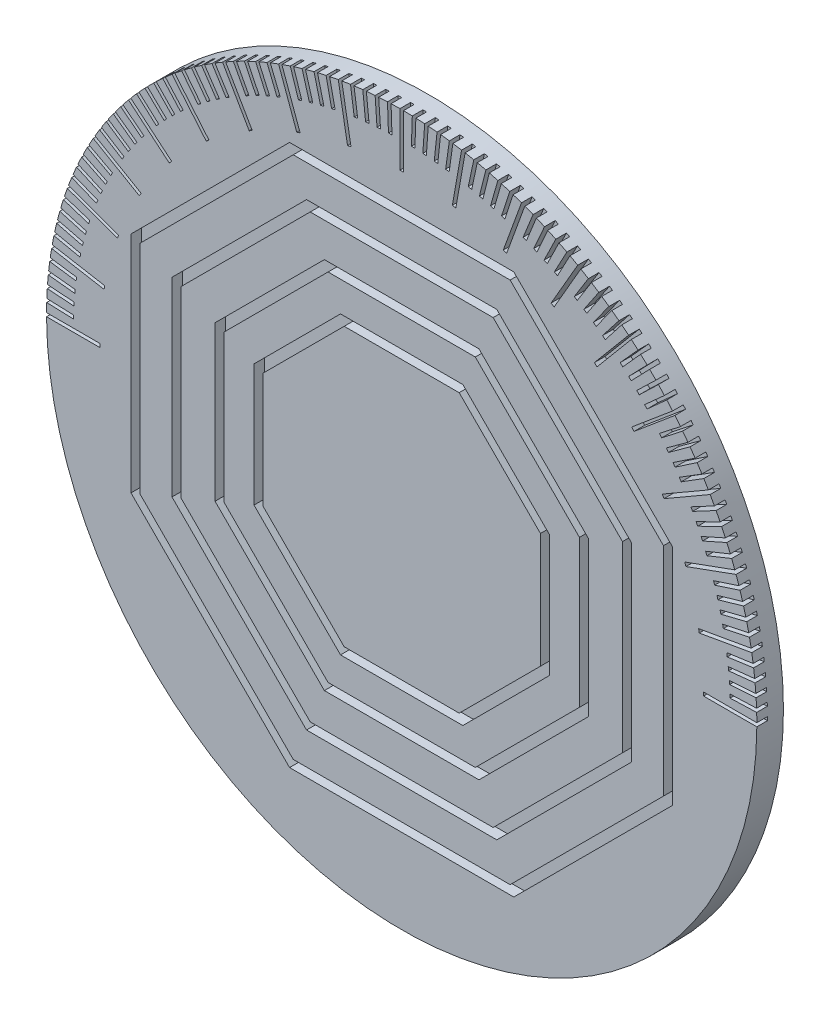
from build123d import *

# Parameters (mm, degrees)
SKETCH_1_R          = 40
EXTRUDE_1_DEPTH     = 3
CUT_EXTRUDE_2_DEPTH = 1.2
SKETCH_6_W          = 3
SKETCH_6_H          = 0.4
SKETCH_6_W_2        = 0.4
SKETCH_6_H_2        = 3
CUT_EXTRUDE_5_DEPTH = 1.2
SKETCH_4_W          = 6
SKETCH_4_H          = 0.4
SKETCH_4_W_2        = 0.4
SKETCH_4_H_2        = 6
CUT_EXTRUDE_7_DEPTH = 1.2


with BuildPart() as part:
    # 스케치1 → 보스-돌출1 (new body)
    with BuildSketch(Plane.XY):
        Circle(SKETCH_1_R)
    extrude(amount=EXTRUDE_1_DEPTH)

    # 스케치3 → 컷-돌출2 (cut)
    # profile 1 of 4: a face of its own
    with BuildSketch(Plane.XY.offset(3)):
        Polygon((-12.628553268, -30.488024573), (12.628553268, -30.488024573), (30.488024573, -12.628553268), (30.488024573, 12.628553268), (12.628553268, 30.488024573), (-12.628553268, 30.488024573), (-30.488024573, 12.628553268), (-30.488024573, -12.628553268), align=None)
        Polygon((29.488024573, -12.214339706), (12.214339706, -29.488024573), (-12.214339706, -29.488024573), (-29.488024573, -12.214339706), (-29.488024573, 12.214339706), (-12.214339706, 29.488024573), (12.214339706, 29.488024573), (29.488024573, 12.214339706), align=None, mode=Mode.SUBTRACT)
    # profile 2 of 4: a face of its own
    with BuildSketch(Plane.XY.offset(3)):
        Polygon((10.715136106, 25.86862691), (-10.715136106, 25.86862691), (-25.86862691, 10.715136106), (-25.86862691, -10.715136106), (-10.715136106, -25.86862691), (10.715136106, -25.86862691), (25.86862691, -10.715136106), (25.86862691, 10.715136106), align=None)
        Polygon((-24.86862691, 10.300922544), (-10.300922544, 24.86862691), (10.300922544, 24.86862691), (24.86862691, 10.300922544), (24.86862691, -10.300922544), (10.300922544, -24.86862691), (-10.300922544, -24.86862691), (-24.86862691, -10.300922544), align=None, mode=Mode.SUBTRACT)
    # profile 3 of 4: a face of its own
    with BuildSketch(Plane.XY.offset(3)):
        Polygon((8.706048086, 21.018259365), (-8.706048086, 21.018259365), (-21.018259365, 8.706048086), (-21.018259365, -8.706048086), (-8.706048086, -21.018259365), (8.706048086, -21.018259365), (21.018259365, -8.706048086), (21.018259365, 8.706048086), align=None)
        Polygon((-20.018259365, 8.291834524), (-8.291834524, 20.018259365), (8.291834524, 20.018259365), (20.018259365, 8.291834524), (20.018259365, -8.291834524), (8.291834524, -20.018259365), (-8.291834524, -20.018259365), (-20.018259365, -8.291834524), align=None, mode=Mode.SUBTRACT)
    # profile 4 of 4: a face of its own
    with BuildSketch(Plane.XY.offset(3)):
        Polygon((-6.888301783, -16.629831585), (6.888301783, -16.629831585), (16.629831585, -6.888301783), (16.629831585, 6.888301783), (6.888301783, 16.629831585), (-6.888301783, 16.629831585), (-16.629831585, 6.888301783), (-16.629831585, -6.888301783), align=None)
        Polygon((15.629831585, -6.47408822), (6.47408822, -15.629831585), (-6.47408822, -15.629831585), (-15.629831585, -6.47408822), (-15.629831585, 6.47408822), (-6.47408822, 15.629831585), (6.47408822, 15.629831585), (15.629831585, 6.47408822), align=None, mode=Mode.SUBTRACT)
    extrude(amount=-CUT_EXTRUDE_2_DEPTH, mode=Mode.SUBTRACT)

    # 스케치6 → 컷-돌출5 (cut)
    with BuildSketch(Plane.XY.offset(3)):
        with Locations((-38.5, 0)):
            Rectangle(SKETCH_6_W, SKETCH_6_H)
        Polygon((-39.968653181, 1.595858034), (-39.98261298, 1.196101703), (-36.984440499, 1.091403213), (-36.9704807, 1.491159543), align=None)
        Polygon((-39.888610716, 2.98977176), (-39.916513305, 2.59074614), (-36.923821154, 2.381476718), (-36.895918565, 2.780502339), align=None)
        Polygon((-39.759970122, 4.38004291), (-39.801781507, 3.982234152), (-36.818215821, 3.668648762), (-36.776404436, 4.06645752), align=None)
        Polygon((-39.582888129, 5.764977652), (-39.63855737, 5.368870425), (-36.667753164, 4.951351122), (-36.612083923, 5.347458349), align=None)
        Polygon((-39.357580485, 7.142888657), (-39.427039756, 6.748965556), (-36.472616497, 6.228021023), (-36.403157226, 6.621944124), align=None)
        Polygon((-39.084321691, 8.512097153), (-39.167486368, 8.120838113), (-36.233043565, 7.49710304), (-36.149878889, 7.88836208), align=None)
        Polygon((-38.763444672, 9.870934969), (-38.86021343, 9.482816679), (-35.949326251, 8.757050992), (-35.852557493, 9.145169282), align=None)
        Polygon((-38.395340366, 11.217746572), (-38.505595309, 10.833241893), (-35.621810221, 10.006329826), (-35.511555279, 10.390834504), align=None)
        Polygon((-37.980457253, 12.550891078), (-38.104064051, 12.170468472), (-35.250894502, 11.243417489), (-35.127287704, 11.623840095), align=None)
        Polygon((-37.519300803, 13.868744257), (-37.65610886, 13.492867209), (-34.837030998, 12.466806779), (-34.70022294, 12.842683827), align=None)
        Polygon((-37.012432864, 15.169700508), (-37.162275501, 14.798826966), (-34.380723938, 13.675007185), (-34.2308813, 14.045880727), align=None)
        Polygon((-36.460470977, 16.452174815), (-36.623165634, 16.086756632), (-33.882529261, 14.866546702), (-33.719834604, 15.231964885), align=None)
        Polygon((-35.864087623, 17.714604681), (-36.039436081, 17.355087062), (-33.343053942, 16.039973622), (-33.167705484, 16.39949124), align=None)
        Polygon((-35.224009402, 18.95545203), (-35.411798027, 18.602272993), (-32.762955248, 17.193858305), (-32.575166623, 17.547037342), align=None)
        Polygon((-34.541016151, 20.173205081), (-34.741016151, 19.826794919), (-32.14293994, 18.326794919), (-31.94293994, 18.673205081), align=None)
        Polygon((-33.815939993, 21.366380189), (-34.027907699, 21.02716095), (-31.483763411, 19.437403157), (-31.271795705, 19.776622396), align=None)
        Polygon((-33.049664322, 22.533523653), (-33.273341483, 22.201908624), (-30.786228765, 20.524329914), (-30.562551604, 20.855944943), align=None)
        Polygon((-32.243122725, 23.673213491), (-32.478236825, 23.349606693), (-30.051185842, 21.586250936), (-29.816071741, 21.909857734), align=None)
        Polygon((-31.397297849, 24.784061164), (-31.643562439, 24.468856862), (-29.279530179, 22.621872436), (-29.033265588, 22.937076738), align=None)
        Polygon((-30.513220203, 25.864713276), (-30.770335247, 25.558295499), (-28.472201917, 23.62993267), (-28.215086873, 23.936350447), align=None)
        Polygon((-29.591966898, 26.913853219), (-29.85961914, 26.616595289), (-27.630184664, 24.60920347), (-27.362532421, 24.9064614), align=None)
        Polygon((-28.634660339, 27.930202778), (-28.912523688, 27.642466858), (-26.754504287, 25.558491747), (-26.476640938, 25.846227667), align=None)
        Polygon((-27.642466858, 28.912523688), (-27.930202778, 28.634660339), (-25.846227667, 26.476640938), (-25.558491747, 26.754504287), align=None)
        Polygon((-26.616595289, 29.85961914), (-26.913853219, 29.591966898), (-24.9064614, 27.362532421), (-24.60920347, 27.630184664), align=None)
        Polygon((-25.558295499, 30.770335247), (-25.864713276, 30.513220203), (-23.936350447, 28.215086873), (-23.62993267, 28.472201917), align=None)
        Polygon((-24.468856862, 31.643562439), (-24.784061164, 31.397297849), (-22.937076738, 29.033265588), (-22.621872436, 29.279530179), align=None)
        Polygon((-23.349606693, 32.478236825), (-23.673213491, 32.243122725), (-21.909857734, 29.816071741), (-21.586250936, 30.051185842), align=None)
        Polygon((-22.201908624, 33.273341483), (-22.533523653, 33.049664322), (-20.855944943, 30.562551604), (-20.524329914, 30.786228765), align=None)
        Polygon((-21.02716095, 34.027907699), (-21.366380189, 33.815939993), (-19.776622396, 31.271795705), (-19.437403157, 31.483763411), align=None)
        Polygon((-19.826794919, 34.741016151), (-20.173205081, 34.541016151), (-18.673205081, 31.94293994), (-18.326794919, 32.14293994), align=None)
        Polygon((-18.602272993, 35.411798027), (-18.95545203, 35.224009402), (-17.547037342, 32.575166623), (-17.193858305, 32.762955248), align=None)
        Polygon((-17.355087062, 36.039436081), (-17.714604681, 35.864087623), (-16.39949124, 33.167705484), (-16.039973622, 33.343053942), align=None)
        Polygon((-16.086756632, 36.623165634), (-16.452174815, 36.460470977), (-15.231964885, 33.719834604), (-14.866546702, 33.882529261), align=None)
        Polygon((-14.798826966, 37.162275501), (-15.169700508, 37.012432864), (-14.045880727, 34.2308813), (-13.675007185, 34.380723938), align=None)
        Polygon((-13.492867209, 37.65610886), (-13.868744257, 37.519300803), (-12.842683827, 34.70022294), (-12.466806779, 34.837030998), align=None)
        Polygon((-12.170468472, 38.104064051), (-12.550891078, 37.980457253), (-11.623840095, 35.127287704), (-11.243417489, 35.250894502), align=None)
        Polygon((-10.833241893, 38.505595309), (-11.217746572, 38.395340366), (-10.390834504, 35.511555279), (-10.006329826, 35.621810221), align=None)
        Polygon((-9.482816679, 38.86021343), (-9.870934969, 38.763444672), (-9.145169282, 35.852557493), (-8.757050992, 35.949326251), align=None)
        Polygon((-8.120838113, 39.167486368), (-8.512097153, 39.084321691), (-7.88836208, 36.149878889), (-7.49710304, 36.233043565), align=None)
        Polygon((-6.748965556, 39.427039756), (-7.142888657, 39.357580485), (-6.621944124, 36.403157226), (-6.228021023, 36.472616497), align=None)
        Polygon((-5.368870425, 39.63855737), (-5.764977652, 39.582888129), (-5.347458349, 36.612083923), (-4.951351122, 36.667753164), align=None)
        Polygon((-3.982234152, 39.801781507), (-4.38004291, 39.759970122), (-4.06645752, 36.776404436), (-3.668648762, 36.818215821), align=None)
        Polygon((-2.59074614, 39.916513305), (-2.98977176, 39.888610716), (-2.780502339, 36.895918565), (-2.381476718, 36.923821154), align=None)
        Polygon((-1.196101703, 39.98261298), (-1.595858034, 39.968653181), (-1.491159543, 36.9704807), (-1.091403213, 36.984440499), align=None)
        with Locations((0, 38.5)):
            Rectangle(SKETCH_6_W_2, SKETCH_6_H_2)
        Polygon((1.595858033, 39.968653181), (1.196101703, 39.98261298), (1.091403213, 36.984440499), (1.491159543, 36.9704807), align=None)
        Polygon((2.98977176, 39.888610716), (2.59074614, 39.916513305), (2.381476718, 36.923821154), (2.780502339, 36.895918565), align=None)
        Polygon((4.38004291, 39.759970122), (3.982234152, 39.801781507), (3.668648762, 36.818215821), (4.06645752, 36.776404436), align=None)
        Polygon((5.764977652, 39.582888129), (5.368870425, 39.63855737), (4.951351122, 36.667753164), (5.347458349, 36.612083923), align=None)
        Polygon((7.142888657, 39.357580485), (6.748965556, 39.427039756), (6.228021023, 36.472616497), (6.621944124, 36.403157226), align=None)
        Polygon((8.512097153, 39.084321691), (8.120838113, 39.167486368), (7.49710304, 36.233043565), (7.88836208, 36.149878889), align=None)
        Polygon((9.870934969, 38.763444672), (9.482816679, 38.86021343), (8.757050992, 35.949326251), (9.145169282, 35.852557493), align=None)
        Polygon((11.217746572, 38.395340366), (10.833241893, 38.505595309), (10.006329826, 35.621810221), (10.390834504, 35.511555279), align=None)
        Polygon((12.550891078, 37.980457253), (12.170468472, 38.104064051), (11.243417489, 35.250894502), (11.623840095, 35.127287704), align=None)
        Polygon((13.868744257, 37.519300803), (13.492867209, 37.65610886), (12.466806779, 34.837030998), (12.842683827, 34.70022294), align=None)
        Polygon((15.169700508, 37.012432864), (14.798826966, 37.162275501), (13.675007185, 34.380723938), (14.045880727, 34.2308813), align=None)
        Polygon((16.452174815, 36.460470977), (16.086756631, 36.623165634), (14.866546702, 33.882529261), (15.231964885, 33.719834604), align=None)
        Polygon((17.714604681, 35.864087623), (17.355087062, 36.039436081), (16.039973622, 33.343053942), (16.39949124, 33.167705484), align=None)
        Polygon((18.95545203, 35.224009402), (18.602272993, 35.411798027), (17.193858304, 32.762955248), (17.547037342, 32.575166623), align=None)
        Polygon((20.173205081, 34.541016151), (19.826794919, 34.741016151), (18.326794919, 32.14293994), (18.673205081, 31.94293994), align=None)
        Polygon((21.366380189, 33.815939993), (21.02716095, 34.027907699), (19.437403157, 31.483763411), (19.776622396, 31.271795705), align=None)
        Polygon((22.533523653, 33.049664322), (22.201908624, 33.273341483), (20.524329914, 30.786228765), (20.855944943, 30.562551604), align=None)
        Polygon((23.673213491, 32.243122725), (23.349606693, 32.478236825), (21.586250936, 30.051185842), (21.909857734, 29.816071741), align=None)
        Polygon((24.784061164, 31.397297849), (24.468856862, 31.643562439), (22.621872436, 29.279530179), (22.937076738, 29.033265588), align=None)
        Polygon((25.864713276, 30.513220203), (25.558295499, 30.770335247), (23.62993267, 28.472201917), (23.936350447, 28.215086873), align=None)
        Polygon((26.913853219, 29.591966898), (26.616595289, 29.85961914), (24.60920347, 27.630184664), (24.9064614, 27.362532421), align=None)
        Polygon((27.930202778, 28.634660339), (27.642466858, 28.912523688), (25.558491747, 26.754504287), (25.846227667, 26.476640938), align=None)
        Polygon((28.912523688, 27.642466858), (28.634660339, 27.930202778), (26.476640938, 25.846227667), (26.754504287, 25.558491747), align=None)
        Polygon((29.85961914, 26.616595289), (29.591966898, 26.913853219), (27.362532421, 24.9064614), (27.630184664, 24.60920347), align=None)
        Polygon((30.770335247, 25.558295499), (30.513220203, 25.864713276), (28.215086873, 23.936350447), (28.472201917, 23.62993267), align=None)
        Polygon((31.643562439, 24.468856862), (31.397297849, 24.784061164), (29.033265588, 22.937076738), (29.279530179, 22.621872436), align=None)
        Polygon((32.478236825, 23.349606693), (32.243122725, 23.673213491), (29.816071741, 21.909857734), (30.051185842, 21.586250936), align=None)
        Polygon((33.273341483, 22.201908624), (33.049664322, 22.533523653), (30.562551604, 20.855944943), (30.786228765, 20.524329914), align=None)
        Polygon((34.027907699, 21.02716095), (33.815939993, 21.366380189), (31.271795705, 19.776622396), (31.483763411, 19.437403157), align=None)
        Polygon((34.741016151, 19.826794919), (34.541016151, 20.173205081), (31.94293994, 18.673205081), (32.14293994, 18.326794919), align=None)
        Polygon((35.411798027, 18.602272993), (35.224009402, 18.95545203), (32.575166623, 17.547037342), (32.762955248, 17.193858305), align=None)
        Polygon((36.039436081, 17.355087062), (35.864087623, 17.714604681), (33.167705484, 16.39949124), (33.343053942, 16.039973622), align=None)
        Polygon((36.623165634, 16.086756632), (36.460470977, 16.452174815), (33.719834604, 15.231964885), (33.882529261, 14.866546702), align=None)
        Polygon((37.162275501, 14.798826966), (37.012432864, 15.169700508), (34.2308813, 14.045880727), (34.380723938, 13.675007185), align=None)
        Polygon((37.65610886, 13.492867209), (37.519300803, 13.868744257), (34.70022294, 12.842683827), (34.837030998, 12.466806779), align=None)
        Polygon((38.104064051, 12.170468472), (37.980457253, 12.550891078), (35.127287704, 11.623840095), (35.250894502, 11.243417489), align=None)
        Polygon((38.505595309, 10.833241894), (38.395340366, 11.217746572), (35.511555279, 10.390834504), (35.621810221, 10.006329826), align=None)
        Polygon((38.86021343, 9.482816679), (38.763444672, 9.870934969), (35.852557493, 9.145169282), (35.949326251, 8.757050992), align=None)
        Polygon((39.167486368, 8.120838113), (39.084321691, 8.512097153), (36.149878889, 7.88836208), (36.233043565, 7.49710304), align=None)
        Polygon((39.427039756, 6.748965556), (39.357580485, 7.142888657), (36.403157226, 6.621944124), (36.472616497, 6.228021023), align=None)
        Polygon((39.63855737, 5.368870425), (39.582888129, 5.764977652), (36.612083923, 5.347458349), (36.667753164, 4.951351122), align=None)
        Polygon((39.801781507, 3.982234152), (39.759970122, 4.38004291), (36.776404436, 4.06645752), (36.818215821, 3.668648762), align=None)
        Polygon((39.916513305, 2.59074614), (39.888610716, 2.98977176), (36.895918565, 2.780502339), (36.923821154, 2.381476718), align=None)
        Polygon((39.98261298, 1.196101703), (39.968653181, 1.595858034), (36.9704807, 1.491159543), (36.984440499, 1.091403213), align=None)
        with Locations((38.5, 0)):
            Rectangle(SKETCH_6_W, SKETCH_6_H)
    extrude(amount=-CUT_EXTRUDE_5_DEPTH, mode=Mode.SUBTRACT)

    # 스케치4 → 컷-돌출7 (cut)
    with BuildSketch(Plane.XY.offset(3)):
        with Locations((-37, 0)):
            Rectangle(SKETCH_4_W, SKETCH_4_H)
        Polygon((-39.357580485, 7.142888657), (-39.427039756, 6.748965556), (-33.518193238, 5.70707649), (-33.448733967, 6.100999591), align=None)
        Polygon((-37.519300803, 13.868744257), (-37.65610886, 13.492867209), (-32.017953135, 11.440746349), (-31.881145078, 11.816623397), align=None)
        Polygon((-34.541016151, 20.173205081), (-34.741016151, 19.826794919), (-29.544863729, 16.826794919), (-29.344863729, 17.173205081), align=None)
        Polygon((-30.513220203, 25.864713276), (-30.770335247, 25.558295499), (-26.174068588, 21.701569841), (-25.916953544, 22.007987618), align=None)
        Polygon((-25.558295499, 30.770335247), (-25.864713276, 30.513220203), (-22.007987618, 25.916953544), (-21.701569841, 26.174068588), align=None)
        Polygon((-19.826794919, 34.741016151), (-20.173205081, 34.541016151), (-17.173205081, 29.344863729), (-16.826794919, 29.544863729), align=None)
        Polygon((-13.492867209, 37.65610886), (-13.868744257, 37.519300803), (-11.816623397, 31.881145078), (-11.440746349, 32.017953135), align=None)
        Polygon((-6.748965556, 39.427039756), (-7.142888657, 39.357580485), (-6.100999591, 33.448733967), (-5.70707649, 33.518193238), align=None)
        with Locations((0, 37)):
            Rectangle(SKETCH_4_W_2, SKETCH_4_H_2)
        Polygon((7.142888657, 39.357580485), (6.748965556, 39.427039756), (5.70707649, 33.518193238), (6.100999591, 33.448733967), align=None)
        Polygon((13.868744257, 37.519300803), (13.492867209, 37.65610886), (11.440746349, 32.017953135), (11.816623397, 31.881145078), align=None)
        Polygon((20.173205081, 34.541016151), (19.826794919, 34.741016151), (16.826794919, 29.544863729), (17.173205081, 29.344863729), align=None)
        Polygon((25.864713276, 30.513220203), (25.558295499, 30.770335247), (21.701569841, 26.174068588), (22.007987618, 25.916953544), align=None)
        Polygon((30.770335247, 25.558295499), (30.513220203, 25.864713276), (25.916953544, 22.007987618), (26.174068588, 21.701569841), align=None)
        Polygon((34.741016151, 19.826794919), (34.541016151, 20.173205081), (29.344863729, 17.173205081), (29.544863729, 16.826794919), align=None)
        Polygon((37.65610886, 13.492867209), (37.519300803, 13.868744257), (31.881145078, 11.816623397), (32.017953135, 11.440746349), align=None)
        Polygon((39.427039756, 6.748965556), (39.357580485, 7.142888657), (33.448733967, 6.100999591), (33.518193238, 5.70707649), align=None)
        with Locations((37, 0)):
            Rectangle(SKETCH_4_W, SKETCH_4_H)
    extrude(amount=-CUT_EXTRUDE_7_DEPTH, mode=Mode.SUBTRACT)


solid = part.part
